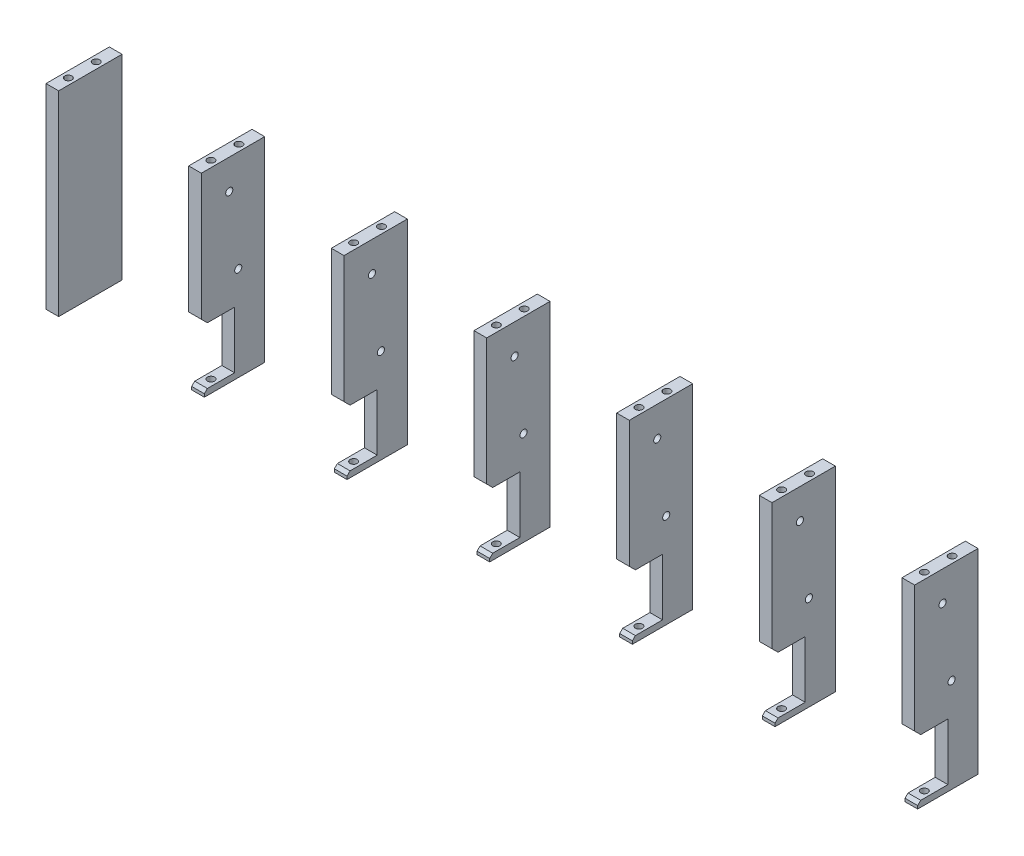
from build123d import *

# Parameters (mm, degrees)
SKETCH2_W             = 6.35
SKETCH2_H             = 98
BOSS_EXTRUDE1_DEPTH   = 31.75
BOSS_EXTRUDE1_2_DEPTH = 31.75
BOSS_EXTRUDE1_3_DEPTH = 31.75
BOSS_EXTRUDE1_4_DEPTH = 31.75
BOSS_EXTRUDE1_5_DEPTH = 31.75
BOSS_EXTRUDE1_6_DEPTH = 31.75
BOSS_EXTRUDE1_7_DEPTH = 31.75
SKETCH3_R             = 1.778
CUT_EXTRUDE1_DEPTH    = 10
SKETCH4_R             = 1.778
CUT_EXTRUDE2_DEPTH    = 10
CUT_EXTRUDE3_DEPTH    = 364.85
SKETCH6_R             = 1.778
CUT_EXTRUDE4_DEPTH    = 364.85


with BuildPart() as part:
    # Sketch2 → Boss-Extrude1 (new body)
    with BuildSketch(Plane.XY.offset(-20)):
        with Locations((-65.916918949, 50)):
            Rectangle(SKETCH2_W, SKETCH2_H)
    extrude(amount=-BOSS_EXTRUDE1_DEPTH)


with BuildPart() as body_2:
    # Sketch2 → Boss-Extrude1 2 (new body)
    with BuildSketch(Plane.XY.offset(-20)):
        with Locations((5.583081051, 50)):
            Rectangle(SKETCH2_W, SKETCH2_H)
    extrude(amount=-BOSS_EXTRUDE1_2_DEPTH)


with BuildPart() as body_3:
    # Sketch2 → Boss-Extrude1 3 (new body)
    with BuildSketch(Plane.XY.offset(-20)):
        with Locations((77.083081051, 50)):
            Rectangle(SKETCH2_W, SKETCH2_H)
    extrude(amount=-BOSS_EXTRUDE1_3_DEPTH)


with BuildPart() as body_4:
    # Sketch2 → Boss-Extrude1 4 (new body)
    with BuildSketch(Plane.XY.offset(-20)):
        with Locations((148.583081051, 50)):
            Rectangle(SKETCH2_W, SKETCH2_H)
    extrude(amount=-BOSS_EXTRUDE1_4_DEPTH)


with BuildPart() as body_5:
    # Sketch2 → Boss-Extrude1 5 (new body)
    with BuildSketch(Plane.XY.offset(-20)):
        with Locations((220.083081051, 50)):
            Rectangle(SKETCH2_W, SKETCH2_H)
    extrude(amount=-BOSS_EXTRUDE1_5_DEPTH)


with BuildPart() as body_6:
    # Sketch2 → Boss-Extrude1 6 (new body)
    with BuildSketch(Plane.XY.offset(-20)):
        with Locations((291.583081051, 50)):
            Rectangle(SKETCH2_W, SKETCH2_H)
    extrude(amount=-BOSS_EXTRUDE1_6_DEPTH)


with BuildPart() as body_7:
    # Sketch2 → Boss-Extrude1 7 (new body)
    with BuildSketch(Plane.XY.offset(-20)):
        with Locations((363.083081051, 50)):
            Rectangle(SKETCH2_W, SKETCH2_H)
    extrude(amount=-BOSS_EXTRUDE1_7_DEPTH)


with BuildPart() as cut_extrude1_tool:
    # Sketch3 → Cut-Extrude1 (new body)
    with BuildSketch(Plane.XZ.offset(-1)):
        with Locations((-65.916918949, -28)):
            Circle(SKETCH3_R)
        with Locations((-65.916918949, -42)):
            Circle(SKETCH3_R)
        with Locations((5.583081051, -28)):
            Circle(SKETCH3_R)
        with Locations((5.583081051, -42)):
            Circle(SKETCH3_R)
        with Locations((77.083081051, -28)):
            Circle(SKETCH3_R)
        with Locations((77.083081051, -42)):
            Circle(SKETCH3_R)
        with Locations((148.583081051, -28)):
            Circle(SKETCH3_R)
        with Locations((148.583081051, -42)):
            Circle(SKETCH3_R)
        with Locations((220.083081051, -28)):
            Circle(SKETCH3_R)
        with Locations((220.083081051, -42)):
            Circle(SKETCH3_R)
        with Locations((291.583081051, -28)):
            Circle(SKETCH3_R)
        with Locations((291.583081051, -42)):
            Circle(SKETCH3_R)
        with Locations((363.083081051, -28)):
            Circle(SKETCH3_R)
        with Locations((363.083081051, -42)):
            Circle(SKETCH3_R)
    extrude(amount=-CUT_EXTRUDE1_DEPTH)


with BuildPart() as part_1:
    add(part.part)

    # Cut-Extrude1: cut by cut_extrude1_tool
    add(cut_extrude1_tool.part, mode=Mode.SUBTRACT)


with BuildPart() as body_2_1:
    add(body_2.part)

    # Cut-Extrude1: cut by cut_extrude1_tool
    add(cut_extrude1_tool.part, mode=Mode.SUBTRACT)


with BuildPart() as body_3_1:
    add(body_3.part)

    # Cut-Extrude1: cut by cut_extrude1_tool
    add(cut_extrude1_tool.part, mode=Mode.SUBTRACT)


with BuildPart() as body_4_1:
    add(body_4.part)

    # Cut-Extrude1: cut by cut_extrude1_tool
    add(cut_extrude1_tool.part, mode=Mode.SUBTRACT)


with BuildPart() as body_5_1:
    add(body_5.part)

    # Cut-Extrude1: cut by cut_extrude1_tool
    add(cut_extrude1_tool.part, mode=Mode.SUBTRACT)


with BuildPart() as body_6_1:
    add(body_6.part)

    # Cut-Extrude1: cut by cut_extrude1_tool
    add(cut_extrude1_tool.part, mode=Mode.SUBTRACT)


with BuildPart() as body_7_1:
    add(body_7.part)

    # Cut-Extrude1: cut by cut_extrude1_tool
    add(cut_extrude1_tool.part, mode=Mode.SUBTRACT)


with BuildPart() as cut_extrude2_tool:
    # Sketch4 → Cut-Extrude2 (new body)
    with BuildSketch(Plane(origin=(0, 99, 0), x_dir=(1, 0, 0), z_dir=(0, 1, 0))):
        with Locations((-65.916918949, 42)):
            Circle(SKETCH4_R)
        with Locations((-65.916918949, 28)):
            Circle(SKETCH4_R)
        with Locations((5.583081051, 42)):
            Circle(SKETCH4_R)
        with Locations((5.583081051, 28)):
            Circle(SKETCH4_R)
        with Locations((77.083081051, 42)):
            Circle(SKETCH4_R)
        with Locations((77.083081051, 28)):
            Circle(SKETCH4_R)
        with Locations((148.583081051, 42)):
            Circle(SKETCH4_R)
        with Locations((148.583081051, 28)):
            Circle(SKETCH4_R)
        with Locations((220.083081051, 42)):
            Circle(SKETCH4_R)
        with Locations((220.083081051, 28)):
            Circle(SKETCH4_R)
        with Locations((291.583081051, 42)):
            Circle(SKETCH4_R)
        with Locations((291.583081051, 28)):
            Circle(SKETCH4_R)
        with Locations((363.083081051, 42)):
            Circle(SKETCH4_R)
        with Locations((363.083081051, 28)):
            Circle(SKETCH4_R)
    extrude(amount=-CUT_EXTRUDE2_DEPTH)


with BuildPart() as part_2:
    add(part_1.part)

    # Cut-Extrude2: cut by cut_extrude2_tool
    add(cut_extrude2_tool.part, mode=Mode.SUBTRACT)


with BuildPart() as body_2_2:
    add(body_2_1.part)

    # Cut-Extrude2: cut by cut_extrude2_tool
    add(cut_extrude2_tool.part, mode=Mode.SUBTRACT)


with BuildPart() as body_3_2:
    add(body_3_1.part)

    # Cut-Extrude2: cut by cut_extrude2_tool
    add(cut_extrude2_tool.part, mode=Mode.SUBTRACT)


with BuildPart() as body_4_2:
    add(body_4_1.part)

    # Cut-Extrude2: cut by cut_extrude2_tool
    add(cut_extrude2_tool.part, mode=Mode.SUBTRACT)


with BuildPart() as body_5_2:
    add(body_5_1.part)

    # Cut-Extrude2: cut by cut_extrude2_tool
    add(cut_extrude2_tool.part, mode=Mode.SUBTRACT)


with BuildPart() as body_6_2:
    add(body_6_1.part)

    # Cut-Extrude2: cut by cut_extrude2_tool
    add(cut_extrude2_tool.part, mode=Mode.SUBTRACT)


with BuildPart() as body_7_2:
    add(body_7_1.part)

    # Cut-Extrude2: cut by cut_extrude2_tool
    add(cut_extrude2_tool.part, mode=Mode.SUBTRACT)


with BuildPart() as cut_extrude3_tool:
    # Sketch5 → Cut-Extrude3 (new body, through all)
    with BuildSketch(Plane.ZY.offset(-2.408081051)):
        Polygon((-20, 32.541440797), (-20, 4.041440797), (-20, 1), (-21.520720398, 1), (-21.520720398, 2.520720398), (-23.041440797, 4.041440797), (-36.653876694, 4.041440797), (-36.653876694, 32.541440797), (-23.041440797, 32.541440797), (-20, 35.582881594), align=None)
    extrude(amount=-CUT_EXTRUDE3_DEPTH)


with BuildPart() as body_2_3:
    add(body_2_2.part)

    # Cut-Extrude3: cut by cut_extrude3_tool
    add(cut_extrude3_tool.part, mode=Mode.SUBTRACT)


with BuildPart() as body_3_3:
    add(body_3_2.part)

    # Cut-Extrude3: cut by cut_extrude3_tool
    add(cut_extrude3_tool.part, mode=Mode.SUBTRACT)


with BuildPart() as body_4_3:
    add(body_4_2.part)

    # Cut-Extrude3: cut by cut_extrude3_tool
    add(cut_extrude3_tool.part, mode=Mode.SUBTRACT)


with BuildPart() as body_5_3:
    add(body_5_2.part)

    # Cut-Extrude3: cut by cut_extrude3_tool
    add(cut_extrude3_tool.part, mode=Mode.SUBTRACT)


with BuildPart() as body_6_3:
    add(body_6_2.part)

    # Cut-Extrude3: cut by cut_extrude3_tool
    add(cut_extrude3_tool.part, mode=Mode.SUBTRACT)


with BuildPart() as body_7_3:
    add(body_7_2.part)

    # Cut-Extrude3: cut by cut_extrude3_tool
    add(cut_extrude3_tool.part, mode=Mode.SUBTRACT)


with BuildPart() as cut_extrude4_tool:
    # Sketch6 → Cut-Extrude4 (new body, through all)
    with BuildSketch(Plane.ZY.offset(-2.408081051)):
        with Locations((-38.5, 48.25)):
            Circle(SKETCH6_R)
        with Locations((-34, 84)):
            Circle(SKETCH6_R)
    extrude(amount=-CUT_EXTRUDE4_DEPTH)


with BuildPart() as body_2_4:
    add(body_2_3.part)

    # Cut-Extrude4: cut by cut_extrude4_tool
    add(cut_extrude4_tool.part, mode=Mode.SUBTRACT)


with BuildPart() as body_3_4:
    add(body_3_3.part)

    # Cut-Extrude4: cut by cut_extrude4_tool
    add(cut_extrude4_tool.part, mode=Mode.SUBTRACT)


with BuildPart() as body_4_4:
    add(body_4_3.part)

    # Cut-Extrude4: cut by cut_extrude4_tool
    add(cut_extrude4_tool.part, mode=Mode.SUBTRACT)


with BuildPart() as body_5_4:
    add(body_5_3.part)

    # Cut-Extrude4: cut by cut_extrude4_tool
    add(cut_extrude4_tool.part, mode=Mode.SUBTRACT)


with BuildPart() as body_6_4:
    add(body_6_3.part)

    # Cut-Extrude4: cut by cut_extrude4_tool
    add(cut_extrude4_tool.part, mode=Mode.SUBTRACT)


with BuildPart() as body_7_4:
    add(body_7_3.part)

    # Cut-Extrude4: cut by cut_extrude4_tool
    add(cut_extrude4_tool.part, mode=Mode.SUBTRACT)


solid = Compound([part_2.part, body_2_4.part, body_3_4.part, body_4_4.part, body_5_4.part, body_6_4.part, body_7_4.part])
